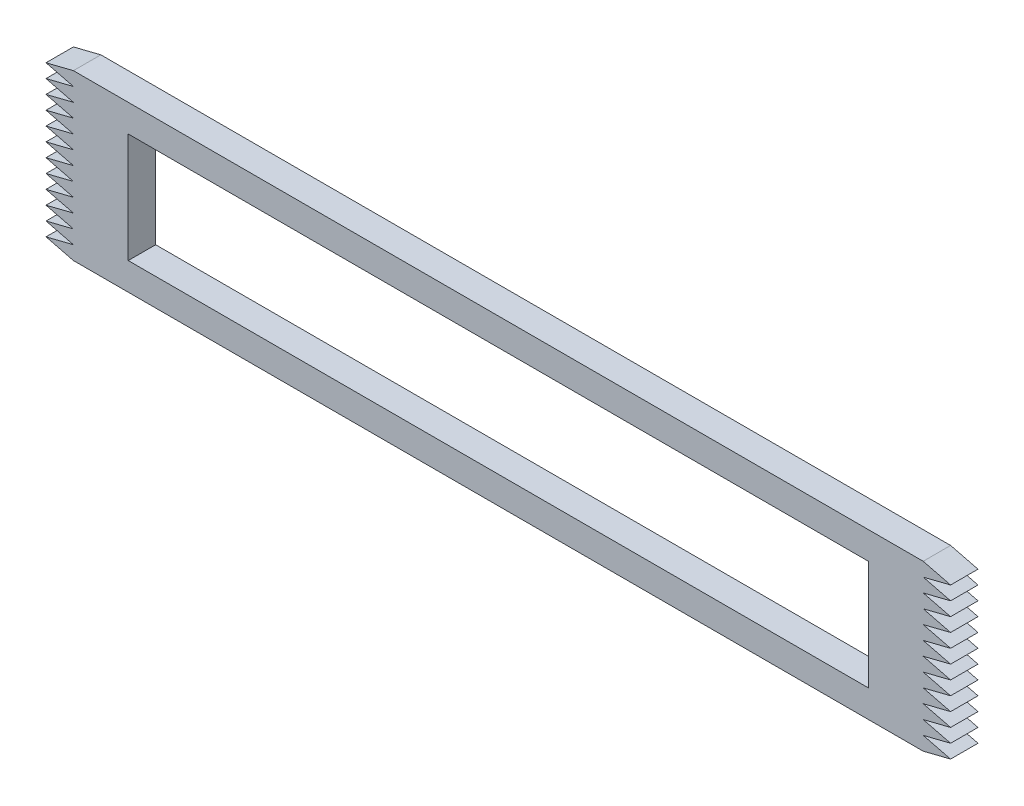
from build123d import *

# Parameters (mm, degrees)
SKETCH1_W           = 171.45
SKETCH1_H           = 25.4
BOSS_EXTRUDE1_DEPTH = 6.35


with BuildPart() as part:
    # Sketch1 → Boss-Extrude1 (new body)
    with BuildSketch(Plane.XY):
        Polygon((-12.7, -6.35), (-19.05, -4.7625), (-12.7, -3.175), (-19.05, -1.5875), (-12.7, 0), (-19.05, 1.5875), (-12.7, 3.175), (-19.05, 4.7625), (-12.7, 6.35), (-19.05, 7.9375), (-12.7, 9.525), (-19.05, 11.1125), (-12.7, 12.7), (-19.05, 14.2875), (-12.7, 15.875), (-19.05, 17.4625), (-12.7, 19.05), (-19.05, 20.6375), (-12.7, 22.225), (-19.05, 23.8125), (-12.7, 25.4), (-19.05, 26.9875), (-12.7, 28.575), (-19.05, 30.1625), (-12.7, 31.75), (184.15, 31.75), (190.5, 30.1625), (184.15, 28.575), (190.5, 26.9875), (184.15, 25.4), (190.5, 23.8125), (184.15, 22.225), (190.5, 20.6375), (184.15, 19.05), (190.5, 17.4625), (184.15, 15.875), (190.5, 14.2875), (184.15, 12.7), (190.5, 11.1125), (184.15, 9.525), (190.5, 7.9375), (184.15, 6.35), (190.5, 4.7625), (184.15, 3.175), (190.5, 1.5875), (184.15, 0), (190.5, -1.5875), (184.15, -3.175), (190.5, -4.7625), (184.15, -6.35), align=None)
        with Locations((85.725, 12.7)):
            Rectangle(SKETCH1_W, SKETCH1_H, mode=Mode.SUBTRACT)
    extrude(amount=BOSS_EXTRUDE1_DEPTH)


solid = part.part
